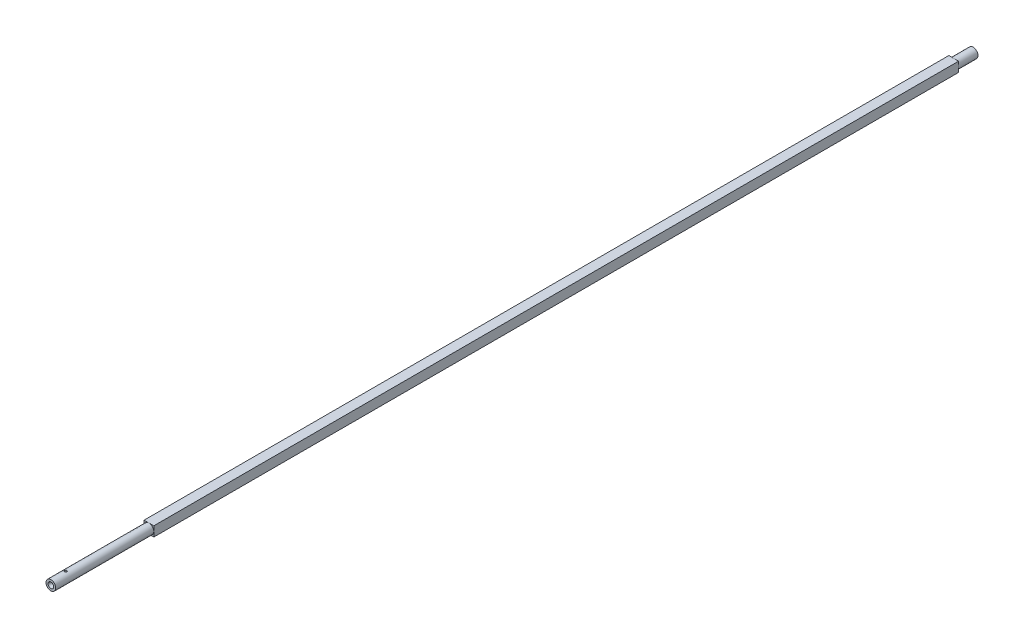
from build123d import *

# Parameters (mm, degrees)
SKETCH2_W               = 6.32
SKETCH2_H               = 6.32
BOSS_EXTRUDE1_DEPTH     = 521.14
SKETCH4_R               = 0.775
CUT_EXTRUDE1_DEPTH      = 4.16
CUT_EXTRUDE1_DEPTH_BACK = 4.16


with BuildPart() as part:
    # Sketch1 → Revolve1 (revolve)
    with BuildSketch(Plane(origin=(0, 0, 0), x_dir=(0, 0, -1), z_dir=(1, 0, 0))):
        Polygon((5, 0), (592.2, 0), (597.2, 1.805), (597.2, 3.155), (0, 3.155), (0, 1.805), align=None)
    revolve(axis=Axis((0, 0, 0), (0, 0, 1)))

    # Sketch2 → Boss-Extrude1 (add)
    with BuildSketch(Plane.XY.offset(-63.5)):
        Rectangle(SKETCH2_W, SKETCH2_H)
    extrude(amount=-BOSS_EXTRUDE1_DEPTH)

    # Sketch4 → Cut-Extrude1 (cut, two sides)
    with BuildSketch(Plane(origin=(0, 0, 0), x_dir=(1, 0, 0), z_dir=(0, 1, 0))) as cut_extrude1_sk:
        with Locations((0, 9.525)):
            Circle(SKETCH4_R)
    extrude(amount=CUT_EXTRUDE1_DEPTH, mode=Mode.SUBTRACT)
    extrude(cut_extrude1_sk.sketch, amount=-CUT_EXTRUDE1_DEPTH_BACK, mode=Mode.SUBTRACT)


solid = part.part
